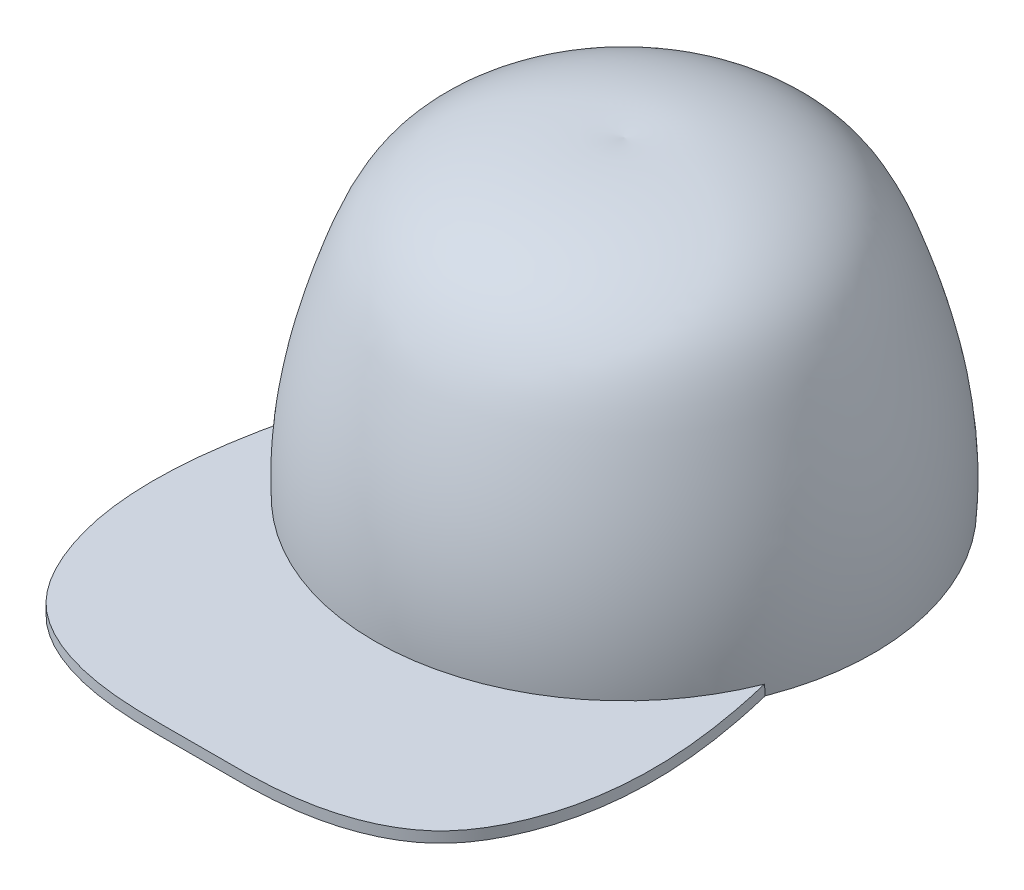
from build123d import *

# Parameters (mm, degrees)
BOSS_EXTRUDE3_DEPTH = 4.18


with BuildPart() as part:
    # Sketch7 → Boss-Extrude3 (new body)
    with BuildSketch(Plane(origin=(0, 0, 0), x_dir=(1, 0, 0), z_dir=(0, 1, 0))):
        with BuildLine():
            ThreePointArc((90, 130.85), (0, 69.491797485), (-90, 130.85))
            add(Edge.make_bspline(
                [(90, 130.85), (97.079309669, 101.675750549), (102.319849387, 59.849101433), (75.220880882, 11.004804432), (38.530319517, -1.069799314), (0, 0.48833618), (-38.530319517, -1.069799314), (-75.220880882, 11.004804432), (-102.319849387, 59.849101433), (-97.079309669, 101.675750549), (-90, 130.85)],
                knots=[0, 0, 0, 0, 0.232377867, 0.29749861, 0.407563265, 0.5, 0.592436735, 0.70250139, 0.767622133, 1, 1, 1, 1], degree=3))
        make_face()
    extrude(amount=BOSS_EXTRUDE3_DEPTH)

    # Sketch9 → Revolve2 (revolve)
    with BuildSketch(Plane(origin=(0, 0, 0), x_dir=(0, 0, -1), z_dir=(1, 0, 0))):
        with BuildLine():
            Line((166.18, 123), (166.18, 125))
            add(Edge.make_bspline(
                [(69.5, 0), (67.581883296, 26.850728663), (75.089030326, 61.070732906), (98.263786833, 120.341869465), (143.498400828, 127.741871184), (166.18, 125)],
                knots=[0, 0, 0, 0, 0.425686615, 0.582159448, 1, 1, 1, 1], degree=3))
            Line((69.5, 0), (71.5, 0))
            add(Edge.make_bspline(
                [(71.5, 0), (69.486543186, 26.977314441), (77.256481199, 60.848403614), (99.616333352, 119.860936938), (144.968117819, 124.95889538), (166.18, 123)],
                knots=[0, 0, 0, 0, 0.43212024, 0.59095793, 1, 1, 1, 1], degree=3))
        make_face()
    revolve(axis=Axis((0, 125, -166.18), (0, -1, 0)))


solid = part.part
